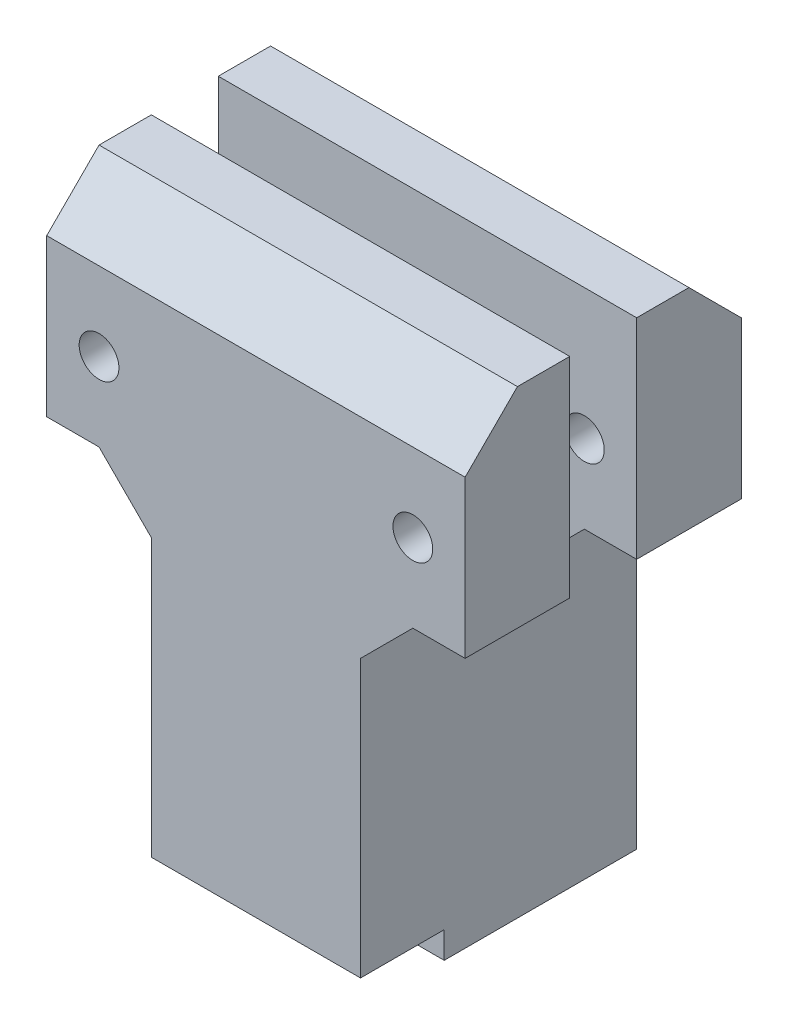
from build123d import *

# Parameters (mm, degrees)
SKETCH1_W             = 25.4
SKETCH1_H             = 12.7
BOSS_EXTRUDE1_DEPTH   = 25.4
BOSS_EXTRUDE1_2_DEPTH = 25.4
SKETCH1_3_W           = 25.4
SKETCH1_3_H           = 33.528
BOSS_EXTRUDE2_DEPTH   = 43.184694682
SKETCH2_W             = 25.4
SKETCH2_H             = 3.2258
CUT_EXTRUDE1_DEPTH    = 10.16
CHAMFER1_SIZE         = 6.35
BOSS_EXTRUDE3_DEPTH   = 12.7
SKETCH6_R             = 2.413
CUT_EXTRUDE3_DEPTH    = 61.284364795
CHAMFER2_SIZE         = 6.35


with BuildPart() as part:
    # Sketch1 → Boss-Extrude1 (new body)
    with BuildSketch(Plane(origin=(0, 0, 0), x_dir=(1, 0, 0), z_dir=(0, 1, 0))):
        with Locations((0, -10.414)):
            Rectangle(SKETCH1_W, SKETCH1_H)
    extrude(amount=BOSS_EXTRUDE1_DEPTH)



with BuildPart() as body_2:
    # Sketch1 → Boss-Extrude1 2 (new body)
    with BuildSketch(Plane(origin=(0, 0, 0), x_dir=(1, 0, 0), z_dir=(0, 1, 0))):
        with Locations((0, 10.414)):
            Rectangle(SKETCH1_W, SKETCH1_H)
    extrude(amount=BOSS_EXTRUDE1_2_DEPTH)


with BuildPart() as part_1:
    add(part.part)

    add(body_2.part)  # Boss-Extrude2 merges body 2
    # Sketch1_3 → Boss-Extrude2 (add)
    with BuildSketch(Plane(origin=(0, 0, 0), x_dir=(1, 0, 0), z_dir=(0, 1, 0))):
        Rectangle(SKETCH1_3_W, SKETCH1_3_H)
    extrude(amount=-BOSS_EXTRUDE2_DEPTH)

    # Sketch2 → Cut-Extrude1 (cut)
    with BuildSketch(Plane.XY.offset(16.764)):
        with Locations((0, -41.571794682)):
            Rectangle(SKETCH2_W, SKETCH2_H)
    extrude(amount=-CUT_EXTRUDE1_DEPTH, mode=Mode.SUBTRACT)

    # Chamfer1
    chamfer1_edges = [part_1.edges().sort_by_distance(p)[0] for p in [
        (0, 25.4, -16.764),
        (0, 25.4, 16.764),
    ]]
    chamfer(chamfer1_edges, length=CHAMFER1_SIZE)

    # Sketch5 → Boss-Extrude3 (add)
    with BuildSketch(Plane.ZY.offset(12.7)):
        Polygon((-10.414, 25.4), (-16.764, 19.05), (-16.764, 0), (-4.064, 0), (-4.064, 25.4), align=None)
        Polygon((4.064, 25.4), (4.064, 0), (16.764, 0), (16.764, 19.05), (10.414, 25.4), align=None)
    boss_extrude3 = extrude(amount=BOSS_EXTRUDE3_DEPTH)

    # Mirror1: Boss-Extrude3 across plane
    add(boss_extrude3.mirror(Plane(origin=(0, 0, 0), x_dir=(0, 0, 1), z_dir=(1, 0, 0))))

    # Sketch6 → Cut-Extrude3 (cut, through all)
    with BuildSketch(Plane.XY.offset(16.764)):
        with Locations((-19.05, 9.525)):
            Circle(SKETCH6_R)
        with Locations((19.05, 9.525)):
            Circle(SKETCH6_R)
    extrude(amount=-CUT_EXTRUDE3_DEPTH, mode=Mode.SUBTRACT)

    # Chamfer2
    chamfer2_edges = [part_1.edges().sort_by_distance(p)[0] for p in [
        (12.7, 0, -10.414),
        (12.7, 0, 10.414),
        (-12.7, 0, -10.414),
        (-12.7, 0, 10.414),
    ]]
    chamfer(chamfer2_edges, length=CHAMFER2_SIZE)


solid = part_1.part
